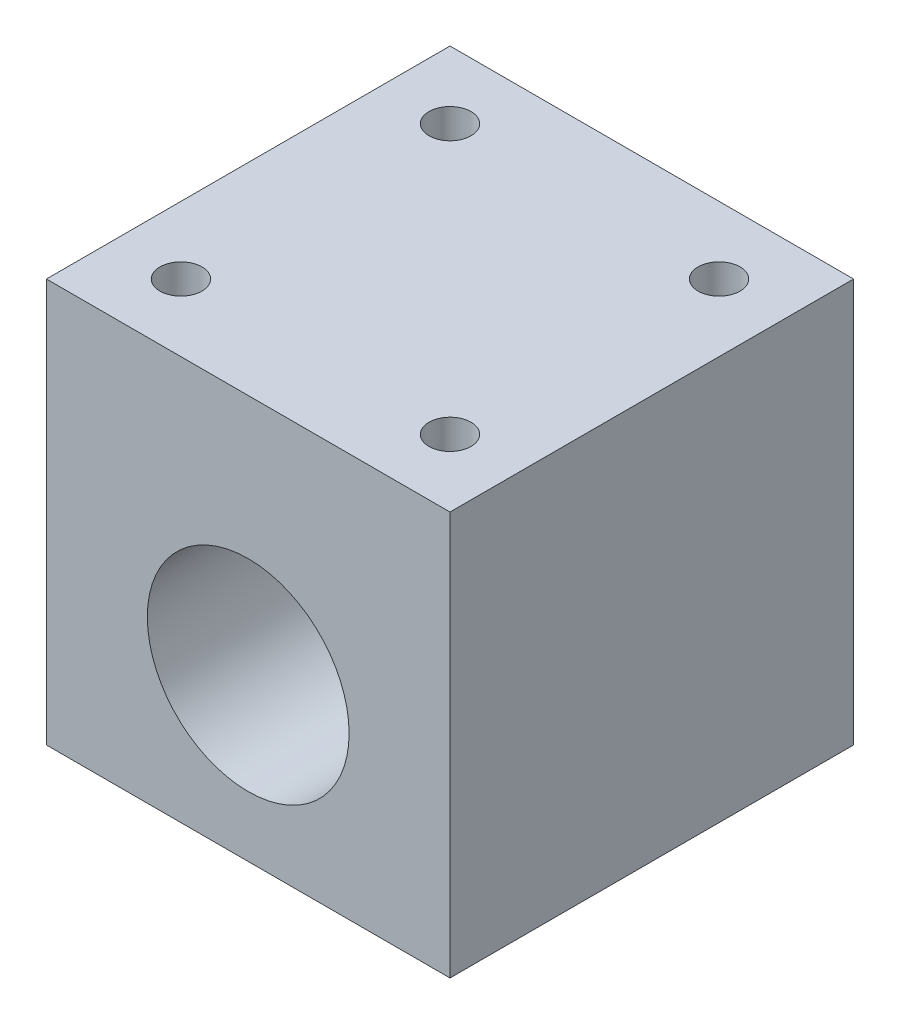
from build123d import *

# Parameters (mm, degrees)
SKETCH1_W                   = 38.1
SKETCH1_H                   = 38.1
BOSS_EXTRUDE1_DEPTH         = 38.1
SKETCH4_R                   = 1.984375
CUT_EXTRUDE2_DEPTH          = 19.05
F_3_4_0_75_DIAMETER_HOLE1_D = 19.05


with BuildPart() as part:
    # Sketch1 → Boss-Extrude1 (new body)
    with BuildSketch(Plane.XY):
        with Locations((19.05, -19.05)):
            Rectangle(SKETCH1_W, SKETCH1_H)
    extrude(amount=BOSS_EXTRUDE1_DEPTH)

    # Sketch4 → Cut-Extrude2 (cut)
    with BuildSketch(Plane(origin=(0, 0, 0), x_dir=(1, 0, 0), z_dir=(0, 1, 0))):
        with Locations((6.35, -6.35)):
            Circle(SKETCH4_R)
        with Locations((6.35, -31.75)):
            Circle(SKETCH4_R)
        with Locations((31.75, -6.35)):
            Circle(SKETCH4_R)
        with Locations((31.75, -31.75)):
            Circle(SKETCH4_R)
    extrude(amount=-CUT_EXTRUDE2_DEPTH, mode=Mode.SUBTRACT)

    # 3/4 (0.75) Diameter Hole1 (through all)
    with Locations(Plane.XY.offset(38.1)):
        with Locations((19.05, -22.86)):
            Hole(F_3_4_0_75_DIAMETER_HOLE1_D / 2)


solid = part.part
